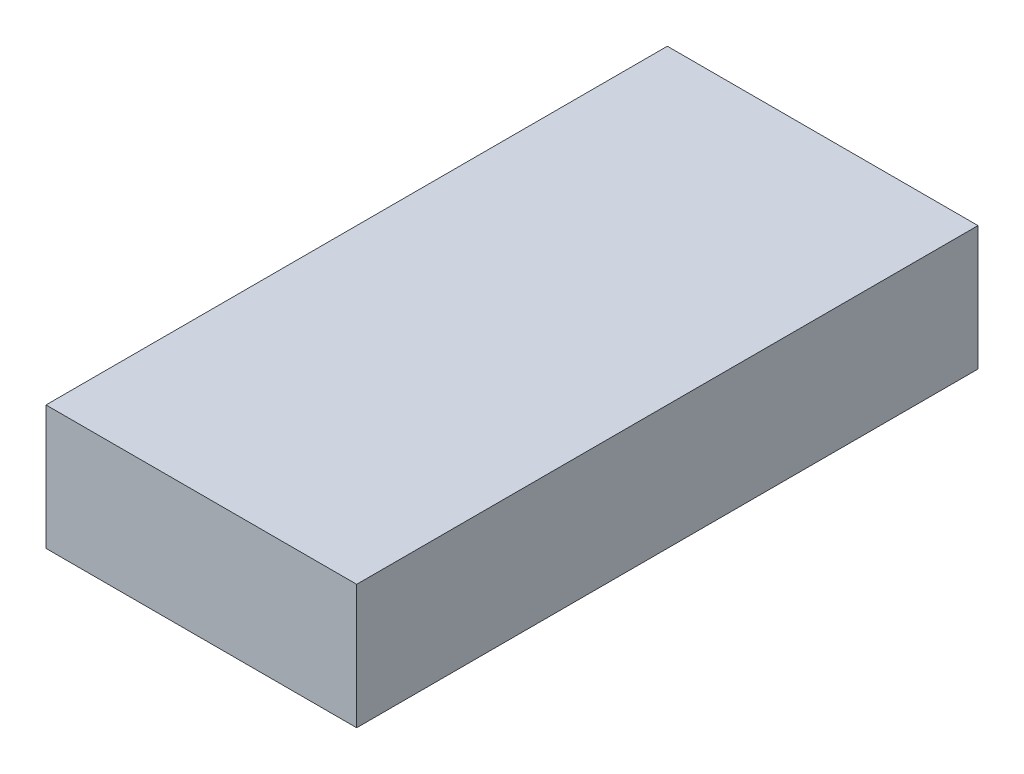
from build123d import *

# Parameters (mm, degrees)
SKETCH_1_W      = 5
SKETCH_1_H      = 10
EXTRUDE_1_DEPTH = 2


with BuildPart() as part:
    # 草图1 → 凸台-拉伸1 (new body)
    with BuildSketch(Plane(origin=(0, 0, 0), x_dir=(1, 0, 0), z_dir=(0, 1, 0))):
        with Locations((2.5, -5)):
            Rectangle(SKETCH_1_W, SKETCH_1_H)
    extrude(amount=EXTRUDE_1_DEPTH)


solid = part.part
